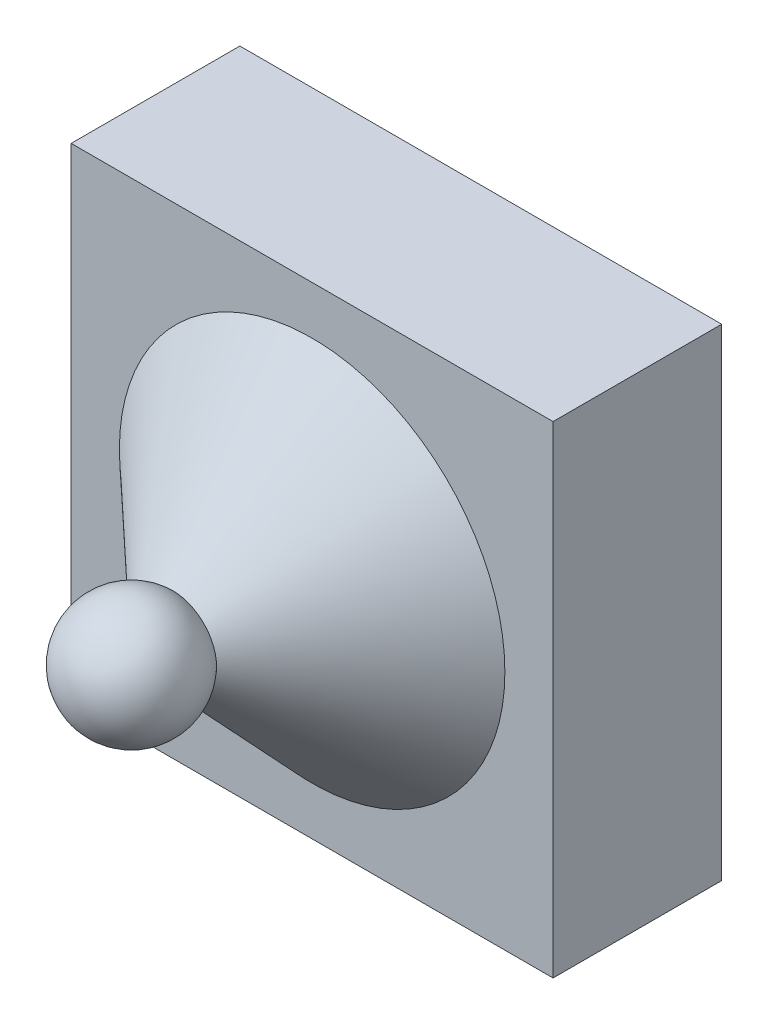
from build123d import *

# Parameters (mm, degrees)
SKETCH1_W           = 100
SKETCH1_H           = 100
BOSS_EXTRUDE1_DEPTH = 35


with BuildPart() as part:
    # Sketch1 → Boss-Extrude1 (new body)
    with BuildSketch(Plane.XY):
        Rectangle(SKETCH1_W, SKETCH1_H)
    extrude(amount=BOSS_EXTRUDE1_DEPTH)

    # Sketch2 → Revolve1 (revolve)
    with BuildSketch(Plane(origin=(0, 0, 0), x_dir=(1, 0, 0), z_dir=(0, 1, 0))):
        with BuildLine():
            Line((0, -35), (0, -72.5))
            Line((0, -72.5), (0, -85))
            ThreePointArc((0, -85), (11.469869254, -77.469114539), (9.119215052, -63.950735889))
            Line((9.119215052, -63.950735889), (40, -35))
            Line((40, -35), (0, -35))
        make_face()
    revolve(axis=Axis((0, 0, 35), (0, 0, 1)))


solid = part.part
